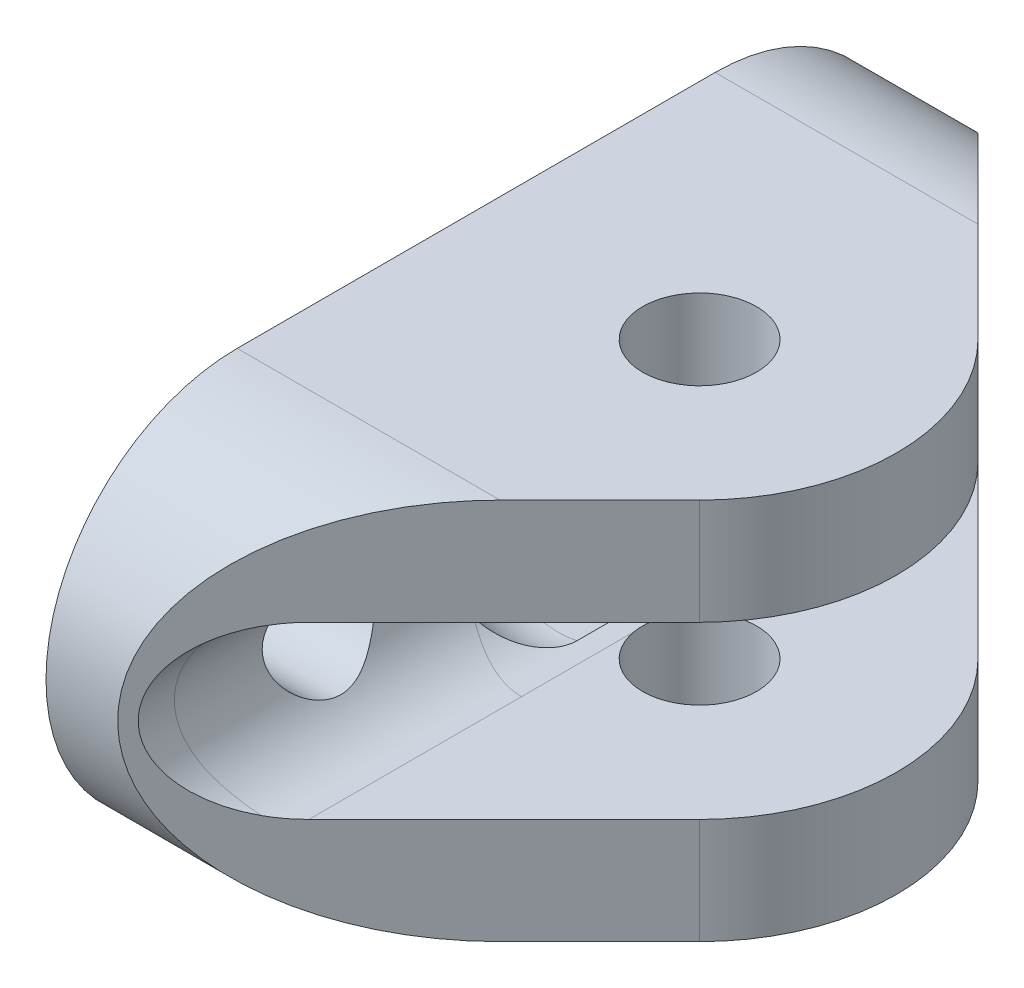
from build123d import *

# Parameters (mm, degrees)
SKETCH1_R               = 4.7625
BOSS_EXTRUDE1_DEPTH     = 50
CUT_EXTRUDE3_DEPTH      = 17
CUT_EXTRUDE3_DEPTH_BACK = 17
SKETCH5_R               = 4.7625
CUT_EXTRUDE2_DEPTH      = 17
CUT_EXTRUDE2_DEPTH_BACK = 17
CUT_EXTRUDE4_DEPTH      = 37
CUT_EXTRUDE4_DEPTH_BACK = 37


with BuildPart() as part:
    # Sketch1 → Boss-Extrude1 (new body)
    with BuildSketch(Plane(origin=(0, 0, 0), x_dir=(0, 0, -1), z_dir=(1, 0, 0))):
        with BuildLine():
            Line((-20, 16), (0, 16))
            Line((0, 16), (20, 16))
            ThreePointArc((20, 16), (36, 0), (20, -16))
            Line((20, -16), (0, -16))
            Line((0, -16), (-20, -16))
            ThreePointArc((-20, -16), (-36, 0), (-20, 16))
        make_face()
        with Locations((-20, 0)):
            Circle(SKETCH1_R, mode=Mode.SUBTRACT)
        with Locations((20, 0)):
            Circle(SKETCH1_R, mode=Mode.SUBTRACT)
    extrude(amount=BOSS_EXTRUDE1_DEPTH)

    # Sketch3 → Cut-Extrude3 (cut, two sides)
    with BuildSketch(Plane(origin=(0, 0, 0), x_dir=(1, 0, 0), z_dir=(0, 1, 0))) as cut_extrude3_sk:
        with BuildLine():
            Line((6, 36), (30.35, 11.65))
            ThreePointArc((30.35, 11.65), (35.175588002, 0), (30.35, -11.65))
            Line((30.35, -11.65), (6, -36))
            Line((6, -36), (6, -40.720576269))
            Line((6, -40.720576269), (53.537884165, -40.720576269))
            Line((53.537884165, -40.720576269), (53.537884165, 49.648939658))
            Line((53.537884165, 49.648939658), (6, 49.648939658))
            Line((6, 49.648939658), (6, 36))
        make_face()
    extrude(amount=CUT_EXTRUDE3_DEPTH, mode=Mode.SUBTRACT)
    extrude(cut_extrude3_sk.sketch, amount=-CUT_EXTRUDE3_DEPTH_BACK, mode=Mode.SUBTRACT)

    # Sketch5 → Cut-Extrude2 (cut, two sides)
    with BuildSketch(Plane(origin=(0, 0, 0), x_dir=(1, 0, 0), z_dir=(0, 1, 0))) as cut_extrude2_sk:
        with Locations((18.7, 0)):
            Circle(SKETCH5_R)
    extrude(amount=CUT_EXTRUDE2_DEPTH, mode=Mode.SUBTRACT)
    extrude(cut_extrude2_sk.sketch, amount=-CUT_EXTRUDE2_DEPTH_BACK, mode=Mode.SUBTRACT)

    # Sketch7 → Cut-Extrude4 (cut, two sides)
    with BuildSketch(Plane.XY) as cut_extrude4_sk:
        with BuildLine():
            Line((56.351176003, -7.14375), (14, -7.14375))
            ThreePointArc((14, -7.14375), (6.85625, 0), (14, 7.14375))
            Line((14, 7.14375), (56.351176003, 7.14375))
            ThreePointArc((56.351176003, 7.14375), (63.494926003, 0), (56.351176003, -7.14375))
        make_face()
    extrude(amount=CUT_EXTRUDE4_DEPTH, mode=Mode.SUBTRACT)
    extrude(cut_extrude4_sk.sketch, amount=-CUT_EXTRUDE4_DEPTH_BACK, mode=Mode.SUBTRACT)

    # Sketch10 → Cut-Revolve1 (revolve, cut)
    with BuildSketch(Plane(origin=(0, 0, 0), x_dir=(1, 0, 0), z_dir=(0, 1, 0))):
        with BuildLine():
            Line((3.7, 4), (3.7, -4))
            ThreePointArc((3.7, -4), (5.794186515, -9.055813485), (10.85, -11.15))
            Line((10.85, -11.15), (10.85, 11.15))
            ThreePointArc((10.85, 11.15), (5.794186515, 9.055813485), (3.7, 4))
        make_face()
    revolve(axis=Axis((10.85, 0, -11.15), (0, 0, 1)), mode=Mode.SUBTRACT)


solid = part.part
